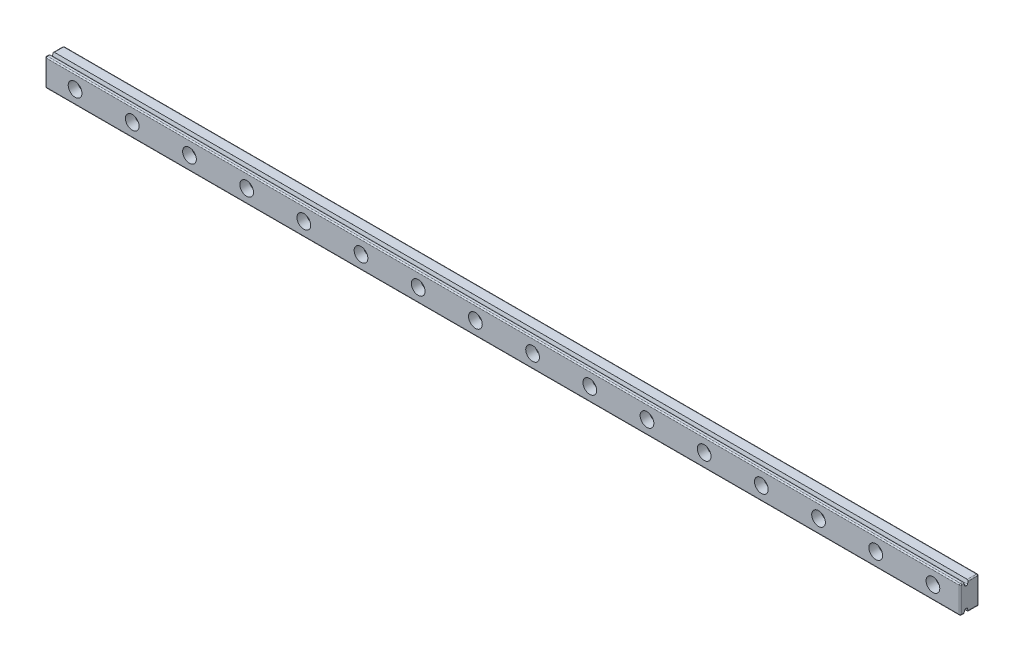
from build123d import *

# Parameters (mm, degrees)
BOSS_EXTRUDE1_DEPTH   = 400
SKETCH2_R             = 1.75
CUT_EXTRUDE1_DEPTH    = 10
SKETCH3_R             = 3
CUT_EXTRUDE2_DEPTH    = 4
CHAMFER1_SIZE         = 0.5
CHAMFER1_SIZE2        = 1.743707222
CHAMFER1_PART_2_SIZE  = 0.5
CHAMFER1_PART_2_SIZE2 = 1.743707222
FILLET1_R             = 0.5


with BuildPart() as part:
    # Sketch1 → Boss-Extrude1 (new body)
    with BuildSketch(Plane(origin=(0, 0, 0), x_dir=(0, 0, -1), z_dir=(1, 0, 0))):
        Polygon((-0.5, 6), (4, 6), (4, -6), (-0.5, -6), (-0.5, -4.25), (-2.5, -4.25), (-2.5, -6), (-4, -6), (-4, 6), (-2.5, 6), (-2.5, 4.25), (-0.5, 4.25), align=None)
    extrude(amount=BOSS_EXTRUDE1_DEPTH)

    # Sketch2 → Cut-Extrude1 (cut)
    with BuildSketch(Plane.XY.offset(4)):
        with Locations((13, 0)):
            Circle(SKETCH2_R)
        with Locations((38, 0)):
            Circle(SKETCH2_R)
        with Locations((63, 0)):
            Circle(SKETCH2_R)
        with Locations((88, 0)):
            Circle(SKETCH2_R)
        with Locations((113, 0)):
            Circle(SKETCH2_R)
        with Locations((138, 0)):
            Circle(SKETCH2_R)
        with Locations((163, 0)):
            Circle(SKETCH2_R)
        with Locations((188, 0)):
            Circle(SKETCH2_R)
        with Locations((213, 0)):
            Circle(SKETCH2_R)
        with Locations((238, 0)):
            Circle(SKETCH2_R)
        with Locations((263, 0)):
            Circle(SKETCH2_R)
        with Locations((288, 0)):
            Circle(SKETCH2_R)
        with Locations((313, 0)):
            Circle(SKETCH2_R)
        with Locations((338, 0)):
            Circle(SKETCH2_R)
        with Locations((363, 0)):
            Circle(SKETCH2_R)
        with Locations((388, 0)):
            Circle(SKETCH2_R)
    extrude(amount=-CUT_EXTRUDE1_DEPTH, mode=Mode.SUBTRACT)

    # Sketch3 → Cut-Extrude2 (cut)
    with BuildSketch(Plane.XY.offset(4)):
        with Locations((13, 0)):
            Circle(SKETCH3_R)
        with Locations((38, 0)):
            Circle(SKETCH3_R)
        with Locations((63, 0)):
            Circle(SKETCH3_R)
        with Locations((88, 0)):
            Circle(SKETCH3_R)
        with Locations((113, 0)):
            Circle(SKETCH3_R)
        with Locations((138, 0)):
            Circle(SKETCH3_R)
        with Locations((163, 0)):
            Circle(SKETCH3_R)
        with Locations((188, 0)):
            Circle(SKETCH3_R)
        with Locations((213, 0)):
            Circle(SKETCH3_R)
        with Locations((238, 0)):
            Circle(SKETCH3_R)
        with Locations((263, 0)):
            Circle(SKETCH3_R)
        with Locations((288, 0)):
            Circle(SKETCH3_R)
        with Locations((313, 0)):
            Circle(SKETCH3_R)
        with Locations((338, 0)):
            Circle(SKETCH3_R)
        with Locations((363, 0)):
            Circle(SKETCH3_R)
        with Locations((388, 0)):
            Circle(SKETCH3_R)
    extrude(amount=-CUT_EXTRUDE2_DEPTH, mode=Mode.SUBTRACT)

    # Chamfer1
    chamfer1_edges = [part.edges().sort_by_distance(p)[0] for p in [
        (200, -4.25, 0.5),
        (200, -4.25, 2.5),
    ]]
    chamfer1_side = [part.faces().sort_by_distance(p)[0] for p in [
        (200, -4.25, 1.5),
    ]]
    chamfer(chamfer1_edges, length=CHAMFER1_SIZE, length2=CHAMFER1_SIZE2, reference=chamfer1_side[0])

    # Chamfer1 part 2
    chamfer1_part_2_edges = [part.edges().sort_by_distance(p)[0] for p in [
        (200, 4.25, 2.5),
        (200, 4.25, 0.5),
    ]]
    chamfer1_part_2_side = [part.faces().sort_by_distance(p)[0] for p in [
        (200, 4.25, 1.5),
    ]]
    chamfer(chamfer1_part_2_edges, length=CHAMFER1_PART_2_SIZE, length2=CHAMFER1_PART_2_SIZE2, reference=chamfer1_part_2_side[0])

    # Fillet1
    fillet1_edges = [part.edges().sort_by_distance(p)[0] for p in [
        (400, -6, -1.75),
        (400, 0, -4),
        (400, 6, -1.75),
        (400, 6, 3.25),
        (400, 0, 4),
        (400, -6, 3.25),
        (0, -6, 3.25),
        (0, -6, -1.75),
        (0, 0, -4),
        (0, 6, -1.75),
        (0, 6, 3.25),
        (0, 0, 4),
        (200, -4.25, 1),
        (200, -4.25, 2),
        (200, 4.25, 2),
        (200, 4.25, 1),
        (200, -6, 4),
        (200, 6, 4),
        (200, -6, -4),
        (200, 6, -4),
    ]]
    fillet(fillet1_edges, radius=FILLET1_R)


solid = part.part
